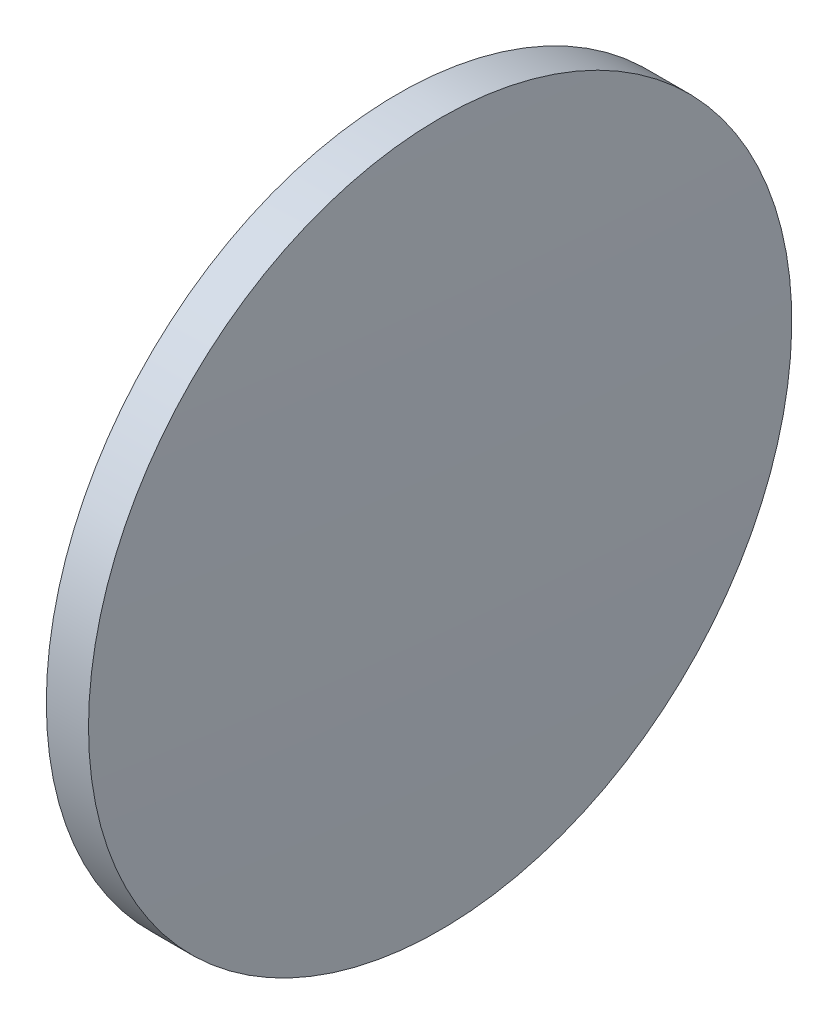
from build123d import *


with BuildPart() as part:
    # 草图1 → 旋转1 (revolve)
    with BuildSketch(Plane.XY):
        with BuildLine():
            Line((408.894387983, 126.2827391), (408.894387983, 138.7827391))
            Line((408.894387983, 138.7827391), (410.394387983, 138.7827391))
            ThreePointArc((410.394387983, 138.7827391), (410.544384783, 132.533539048), (410.594387983, 126.2827391))
            Line((410.594387983, 126.2827391), (408.894387983, 126.2827391))
        make_face()
    revolve(axis=Axis((404.152356741, 126.2827391, 0), (1, 0, 0)))


solid = part.part
